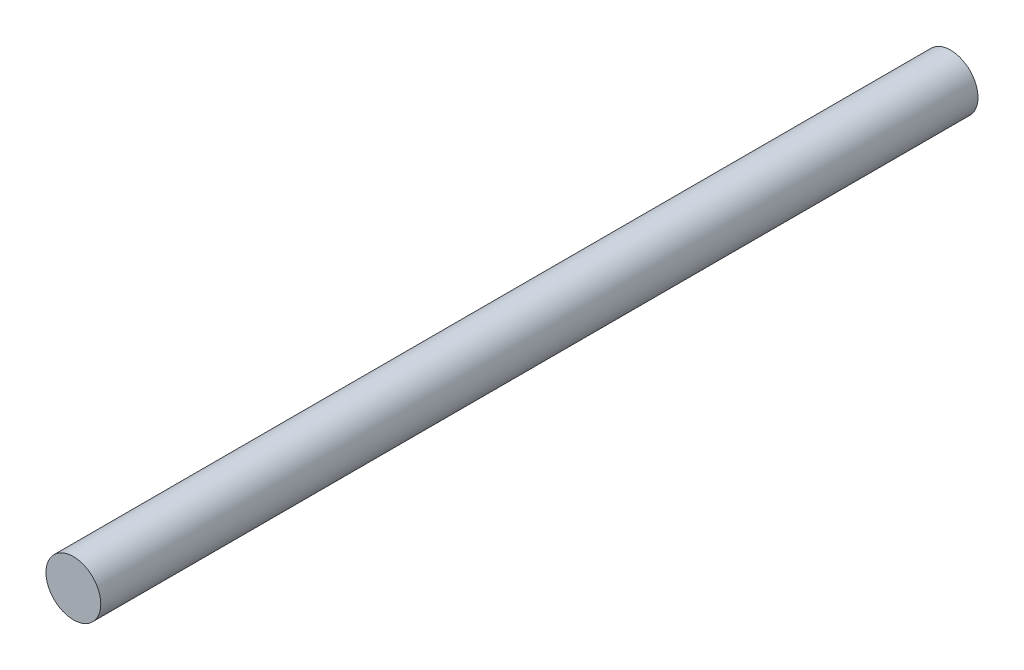
from build123d import *

# Parameters (mm, degrees)
SKETCH1_R           = 1.5875
BOSS_EXTRUDE1_DEPTH = 50.8


with BuildPart() as part:
    # Sketch1 → Boss-Extrude1 (new body)
    with BuildSketch(Plane.XY):
        with Locations((2.831535193, 2.800471084)):
            Circle(SKETCH1_R)
    extrude(amount=BOSS_EXTRUDE1_DEPTH)


solid = part.part
